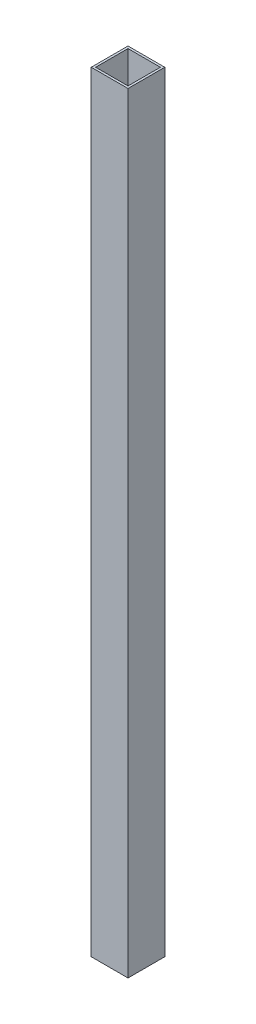
from build123d import *

# Parameters (mm, degrees)
SKETCH1_W           = 50
SKETCH1_H           = 50
SKETCH1_W_2         = 44
SKETCH1_H_2         = 44
BOSS_EXTRUDE1_DEPTH = 1047


with BuildPart() as part:
    # Sketch1 → Boss-Extrude1 (new body)
    with BuildSketch(Plane(origin=(0, 0, 0), x_dir=(1, 0, 0), z_dir=(0, 1, 0))):
        with Locations((25, 25)):
            Rectangle(SKETCH1_W, SKETCH1_H)
        with Locations((25, 25)):
            Rectangle(SKETCH1_W_2, SKETCH1_H_2, mode=Mode.SUBTRACT)
    extrude(amount=BOSS_EXTRUDE1_DEPTH)


solid = part.part
